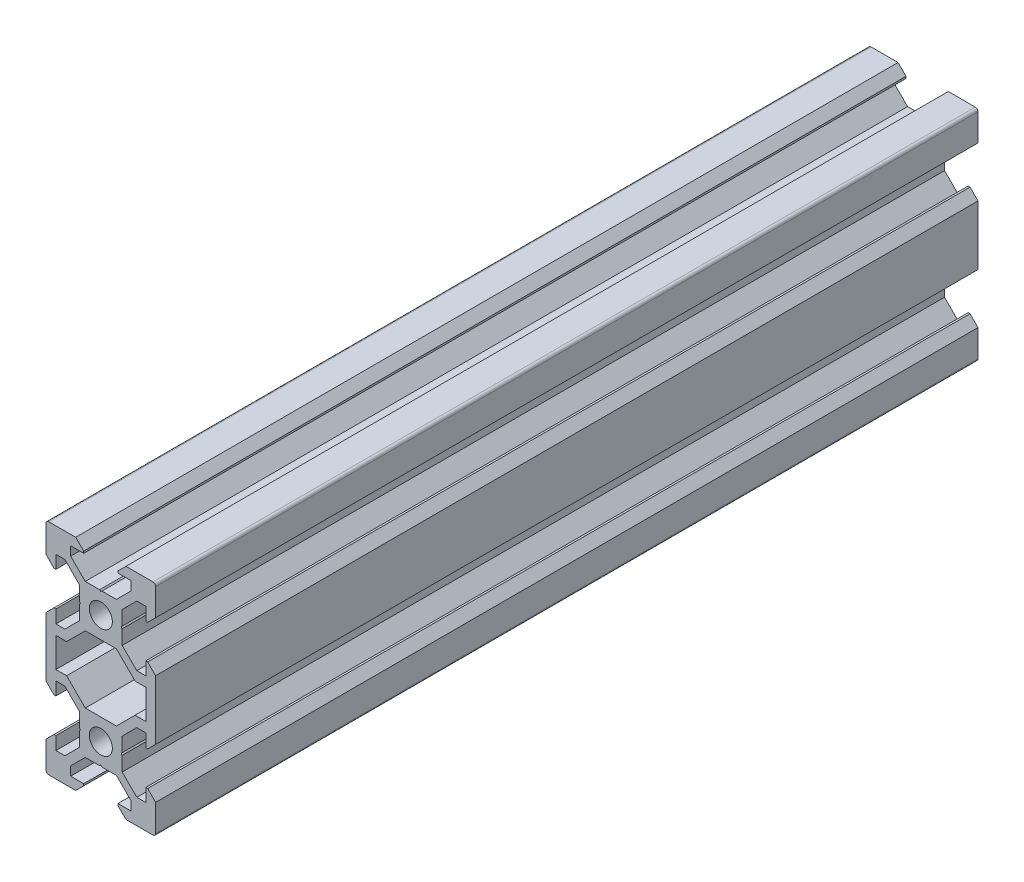
from build123d import *

# Parameters (mm, degrees)
SKETCH1_R           = 2.1
BOSS_EXTRUDE1_DEPTH = 150


with BuildPart() as part:
    # Sketch1 → Boss-Extrude1 (new body)
    with BuildSketch(Plane.XY):
        with BuildLine():
            Line((4.58, -20), (9.5, -20))
            ThreePointArc((9.5, -20), (9.853553391, -19.853553391), (10, -19.5))
            Line((10, -19.5), (10, -14.58))
            Line((10, -14.58), (8.545, -13.125))
            Line((8.545, -13.125), (8.2, -13.125))
            Line((8.2, -13.125), (8.2, -15.5))
            Line((8.2, -15.5), (6.560660172, -15.5))
            Line((6.560660172, -15.5), (3.9, -12.839339828))
            Line((3.9, -12.839339828), (3.9, -10.21))
            Line((3.9, -10.21), (3.69, -10))
            Line((3.69, -10), (3.9, -9.79))
            Line((3.9, -9.79), (3.9, -7.160660172))
            Line((3.9, -7.160660172), (6.560660172, -4.5))
            Line((6.560660172, -4.5), (8.2, -4.5))
            Line((8.2, -4.5), (8.2, -6.875))
            Line((8.2, -6.875), (8.545, -6.875))
            Line((8.545, -6.875), (10, -5.42))
            Line((10, -5.42), (10, 5.42))
            Line((10, 5.42), (8.545, 6.875))
            Line((8.545, 6.875), (8.2, 6.875))
            Line((8.2, 6.875), (8.2, 4.5))
            Line((8.2, 4.5), (6.560660172, 4.5))
            Line((6.560660172, 4.5), (3.9, 7.160660172))
            Line((3.9, 7.160660172), (3.9, 9.79))
            Line((3.9, 9.79), (3.69, 10))
            Line((3.69, 10), (3.9, 10.21))
            Line((3.9, 10.21), (3.9, 12.839339828))
            Line((3.9, 12.839339828), (6.560660172, 15.5))
            Line((6.560660172, 15.5), (8.2, 15.5))
            Line((8.2, 15.5), (8.2, 13.125))
            Line((8.2, 13.125), (8.545, 13.125))
            Line((8.545, 13.125), (10, 14.58))
            Line((10, 14.58), (10, 19.5))
            ThreePointArc((10, 19.5), (9.853553391, 19.853553391), (9.5, 20))
            Line((9.5, 20), (4.58, 20))
            Line((4.58, 20), (3.125, 18.545))
            Line((3.125, 18.545), (3.125, 18.2))
            Line((3.125, 18.2), (5.5, 18.2))
            Line((5.5, 18.2), (5.5, 16.560660172))
            Line((5.5, 16.560660172), (2.839339828, 13.9))
            Line((2.839339828, 13.9), (0.21, 13.9))
            Line((0.21, 13.9), (0, 13.69))
            Line((0, 13.69), (-0.21, 13.9))
            Line((-0.21, 13.9), (-2.839339828, 13.9))
            Line((-2.839339828, 13.9), (-5.5, 16.560660172))
            Line((-5.5, 16.560660172), (-5.5, 18.2))
            Line((-5.5, 18.2), (-3.125, 18.2))
            Line((-3.125, 18.2), (-3.125, 18.545))
            Line((-3.125, 18.545), (-4.58, 20))
            Line((-4.58, 20), (-9.5, 20))
            ThreePointArc((-9.5, 20), (-9.853553391, 19.853553391), (-10, 19.5))
            Line((-10, 19.5), (-10, 14.58))
            Line((-10, 14.58), (-8.545, 13.125))
            Line((-8.545, 13.125), (-8.2, 13.125))
            Line((-8.2, 13.125), (-8.2, 15.5))
            Line((-8.2, 15.5), (-6.560660172, 15.5))
            Line((-6.560660172, 15.5), (-3.9, 12.839339828))
            Line((-3.9, 12.839339828), (-3.9, 10.21))
            Line((-3.9, 10.21), (-3.69, 10))
            Line((-3.69, 10), (-3.9, 9.79))
            Line((-3.9, 9.79), (-3.9, 7.160660172))
            Line((-3.9, 7.160660172), (-6.560660172, 4.5))
            Line((-6.560660172, 4.5), (-8.2, 4.5))
            Line((-8.2, 4.5), (-8.2, 6.875))
            Line((-8.2, 6.875), (-8.545, 6.875))
            Line((-8.545, 6.875), (-10, 5.42))
            Line((-10, 5.42), (-10, -5.42))
            Line((-10, -5.42), (-8.545, -6.875))
            Line((-8.545, -6.875), (-8.2, -6.875))
            Line((-8.2, -6.875), (-8.2, -4.5))
            Line((-8.2, -4.5), (-6.560660172, -4.5))
            Line((-6.560660172, -4.5), (-3.9, -7.160660172))
            Line((-3.9, -7.160660172), (-3.9, -9.79))
            Line((-3.9, -9.79), (-3.69, -10))
            Line((-3.69, -10), (-3.9, -10.21))
            Line((-3.9, -10.21), (-3.9, -12.839339828))
            Line((-3.9, -12.839339828), (-6.560660172, -15.5))
            Line((-6.560660172, -15.5), (-8.2, -15.5))
            Line((-8.2, -15.5), (-8.2, -13.125))
            Line((-8.2, -13.125), (-8.545, -13.125))
            Line((-8.545, -13.125), (-10, -14.58))
            Line((-10, -14.58), (-10, -19.5))
            ThreePointArc((-10, -19.5), (-9.853553391, -19.853553391), (-9.5, -20))
            Line((-9.5, -20), (-4.58, -20))
            Line((-4.58, -20), (-3.125, -18.545))
            Line((-3.125, -18.545), (-3.125, -18.2))
            Line((-3.125, -18.2), (-5.5, -18.2))
            Line((-5.5, -18.2), (-5.5, -16.560660172))
            Line((-5.5, -16.560660172), (-2.839339828, -13.9))
            Line((-2.839339828, -13.9), (-0.21, -13.9))
            Line((-0.21, -13.9), (0, -13.69))
            Line((0, -13.69), (0.21, -13.9))
            Line((0.21, -13.9), (2.839339828, -13.9))
            Line((2.839339828, -13.9), (5.5, -16.560660172))
            Line((5.5, -16.560660172), (5.5, -18.2))
            Line((5.5, -18.2), (3.125, -18.2))
            Line((3.125, -18.2), (3.125, -18.545))
            Line((3.125, -18.545), (4.58, -20))
        make_face()
        with Locations((0, -10)):
            Circle(SKETCH1_R, mode=Mode.SUBTRACT)
        Polygon((-6.239339828, -2.7), (-8.2, -2.7), (-8.2, 2.7), (-6.239339828, 2.7), (-2.839339828, 6.1), (2.839339828, 6.1), (6.239339828, 2.7), (8.2, 2.7), (8.2, -2.7), (6.239339828, -2.7), (2.839339828, -6.1), (-2.839339828, -6.1), align=None, mode=Mode.SUBTRACT)
        with Locations((0, 10)):
            Circle(SKETCH1_R, mode=Mode.SUBTRACT)
    extrude(amount=BOSS_EXTRUDE1_DEPTH)


solid = part.part
